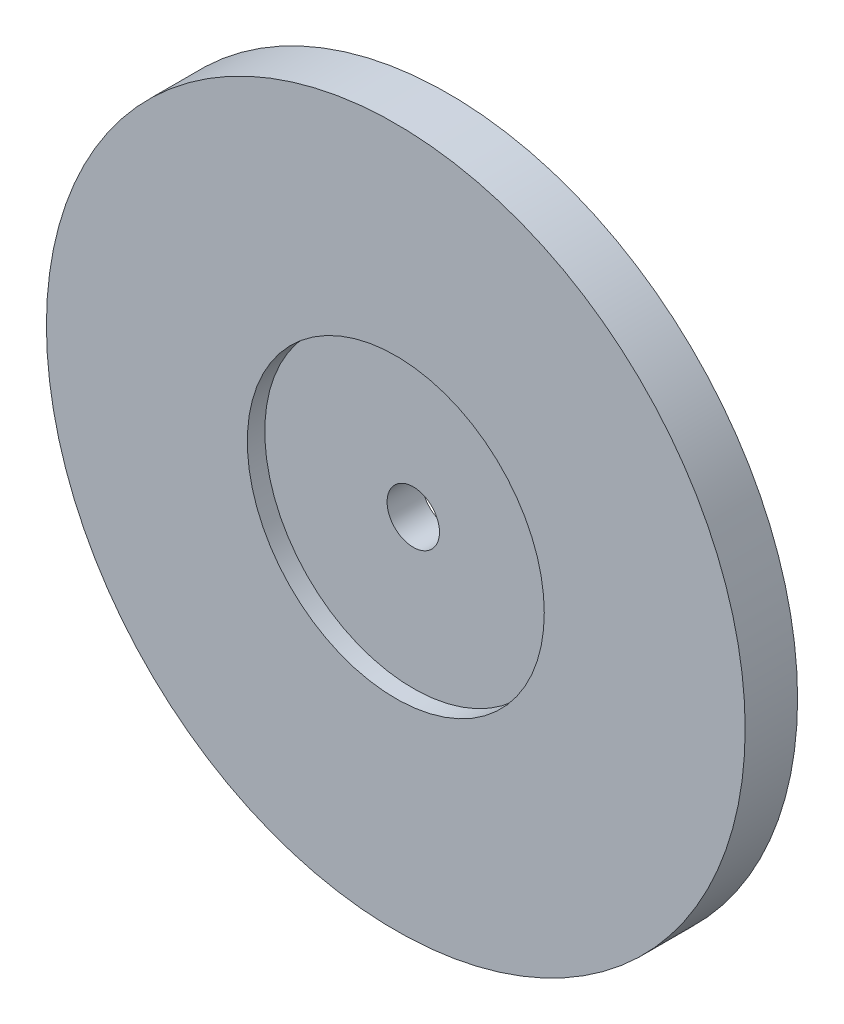
from build123d import *

# Parameters (mm, degrees)
CROQUIS1_R              = 20
CROQUIS1_R_2            = 1.5
SALIENTE_EXTRUIR1_DEPTH = 3
CROQUIS2_R              = 8.5
CORTAR_EXTRUIR1_DEPTH   = 1


with BuildPart() as part:
    # Croquis1 → Saliente-Extruir1 (new body)
    with BuildSketch(Plane.XY):
        with Locations((-67.943036217, 10.163609926)):
            Circle(CROQUIS1_R)
        with Locations((-67.943036217, 10.163609926)):
            Circle(CROQUIS1_R_2, mode=Mode.SUBTRACT)
    extrude(amount=SALIENTE_EXTRUIR1_DEPTH)

    # Croquis2 → Cortar-Extruir1 (cut)
    with BuildSketch(Plane.XY.offset(3)):
        with Locations((-67.943036217, 10.163609926)):
            Circle(CROQUIS2_R)
    extrude(amount=-CORTAR_EXTRUIR1_DEPTH, mode=Mode.SUBTRACT)


solid = part.part
